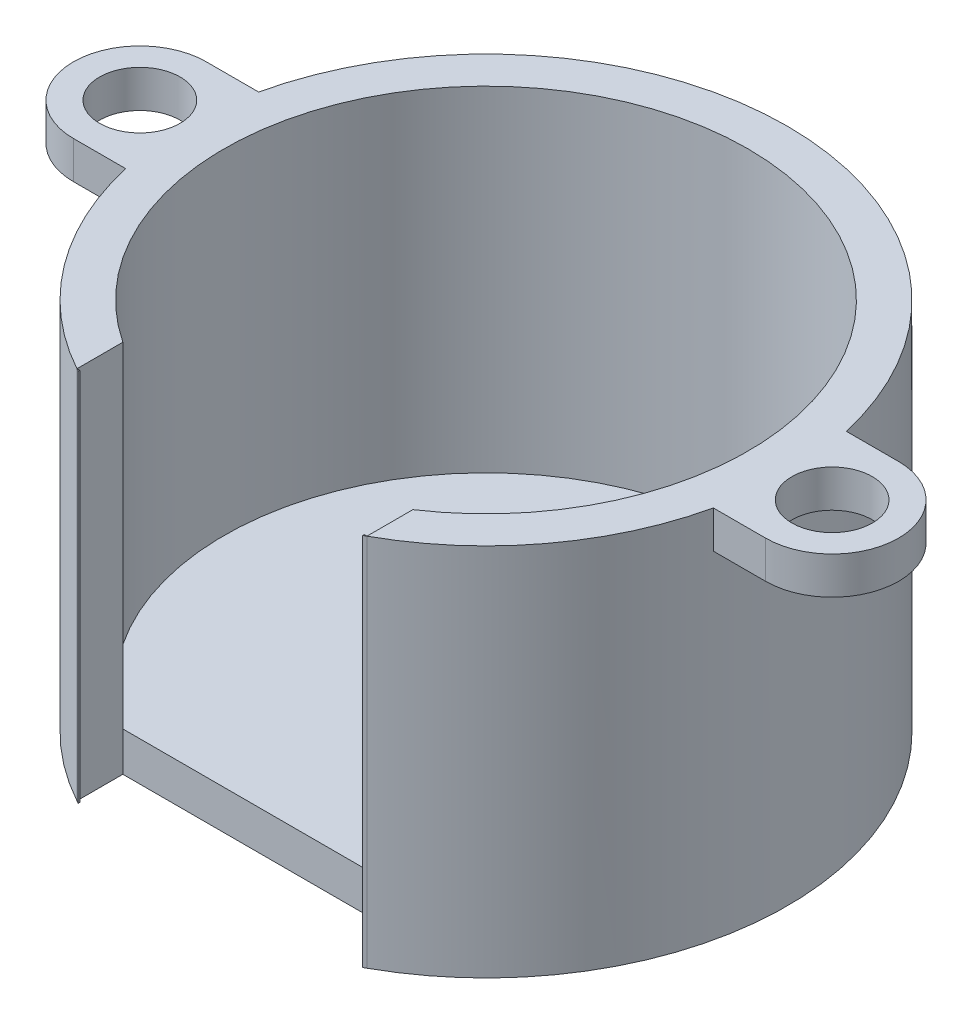
from build123d import *

# Parameters (mm, degrees)
BOSS_EXTRUDE1_DEPTH = 20
SHELL2_T            = -2.1
SKETCH2_R           = 2.15
BOSS_EXTRUDE2_DEPTH = 2
SKETCH3_W           = 15.5
SKETCH3_H           = 2.452739194
CUT_EXTRUDE1_DEPTH  = 21
CUT_EXTRUDE2_REACH  = 32.293
SKETCH4_W           = 15.2
SKETCH4_H           = 20


with BuildPart() as part:
    # Sketch1 → Boss-Extrude1 (new body)
    with BuildSketch(Plane(origin=(0, 0, 0), x_dir=(1, 0, 0), z_dir=(0, 1, 0))):
        with BuildLine():
            Line((-7.6, -14.193308282), (7.6, -14.193308282))
            ThreePointArc((7.6, -14.193308282), (0, 16.1), (-7.6, -14.193308282))
        make_face()
    extrude(amount=BOSS_EXTRUDE1_DEPTH)

    # Shell2
    shell2_openings = [part.faces().sort_by_distance(p)[0] for p in [
        (0, 20, -0.953345859),
    ]]
    offset(amount=SHELL2_T, openings=shell2_openings)

    # Sketch2 → Boss-Extrude2 (add)
    with BuildSketch(Plane(origin=(0, 20, 0), x_dir=(1, 0, 0), z_dir=(0, 1, 0))):
        with BuildLine():
            Line((-15.703741592, 3.55), (-18.5, 3.55))
            ThreePointArc((-18.5, 3.55), (-22.05, 0), (-18.5, -3.55))
            Line((-18.5, -3.55), (-15.703741592, -3.55))
            ThreePointArc((-15.703741592, -3.55), (-16.1, 0), (-15.703741592, 3.55))
        make_face()
        with Locations((-18.5, 0)):
            Circle(SKETCH2_R, mode=Mode.SUBTRACT)
        with BuildLine():
            Line((18.5, 3.55), (15.703741592, 3.55))
            ThreePointArc((15.703741592, 3.55), (16.1, 0), (15.703741592, -3.55))
            Line((15.703741592, -3.55), (18.5, -3.55))
            ThreePointArc((18.5, -3.55), (22.05, 0), (18.5, 3.55))
        make_face()
        with Locations((18.5, 0)):
            Circle(SKETCH2_R, mode=Mode.SUBTRACT)
    extrude(amount=-BOSS_EXTRUDE2_DEPTH)

    # Sketch3 → Cut-Extrude1 (cut, through all)
    with BuildSketch(Plane(origin=(0, 20, 0), x_dir=(1, 0, 0), z_dir=(0, 1, 0))):
        with Locations((0, -12.885593413)):
            Rectangle(SKETCH3_W, SKETCH3_H)
    extrude(amount=-CUT_EXTRUDE1_DEPTH, mode=Mode.SUBTRACT)

    # Sketch4 → Cut-Extrude2 (cut, up to next)
    with BuildSketch(Plane.XY.offset(14.193308282), mode=Mode.PRIVATE) as cut_extrude2_sk1:
        with Locations((0, 10)):
            Rectangle(SKETCH4_W, SKETCH4_H)
    cut_extrude2_tool1 = extrude(cut_extrude2_sk1.sketch, amount=-CUT_EXTRUDE2_REACH, mode=Mode.PRIVATE) & part.part
    add(cut_extrude2_tool1.solids().sort_by_distance((0, 10, 14.193308))[0], mode=Mode.SUBTRACT)


solid = part.part
